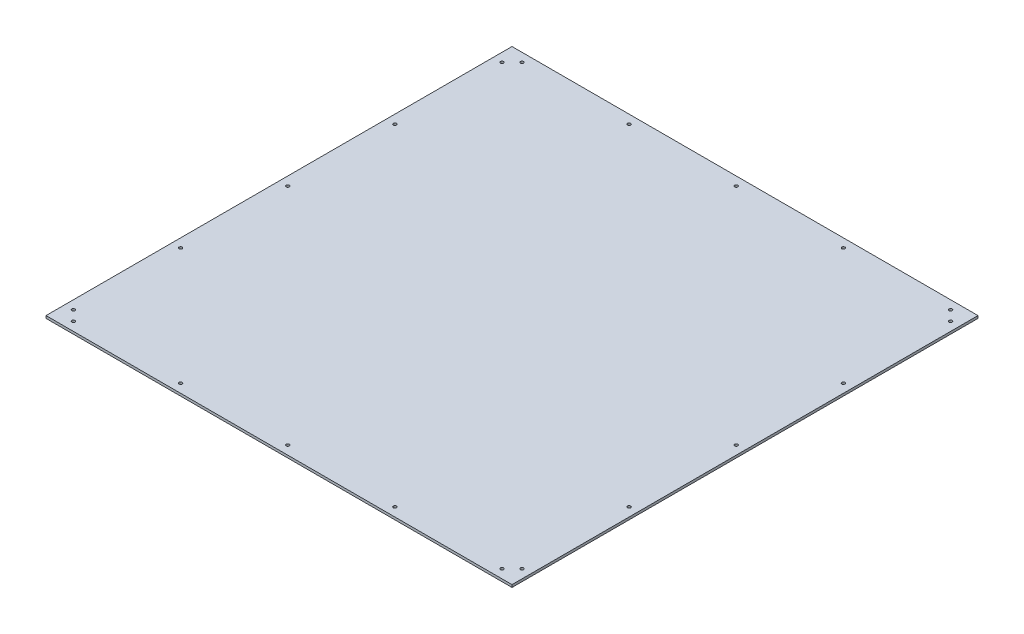
from build123d import *

# Parameters (mm, degrees)
SKETCH1_W           = 748
SKETCH1_H           = 748
SKETCH1_R           = 2.5
BOSS_EXTRUDE1_DEPTH = 4


with BuildPart() as part:
    # Sketch1 → Boss-Extrude1 (new body)
    with BuildSketch(Plane(origin=(0, 0, 0), x_dir=(1, 0, 0), z_dir=(0, 1, 0))):
        Rectangle(SKETCH1_W, SKETCH1_H)
        with Locations((-344, 360)):
            Circle(SKETCH1_R, mode=Mode.SUBTRACT)
        with Locations((0, 360)):
            Circle(SKETCH1_R, mode=Mode.SUBTRACT)
        with Locations((-172, 360)):
            Circle(SKETCH1_R, mode=Mode.SUBTRACT)
        with Locations((-360, 0)):
            Circle(SKETCH1_R, mode=Mode.SUBTRACT)
        with Locations((-360, 172)):
            Circle(SKETCH1_R, mode=Mode.SUBTRACT)
        with Locations((-360, 344)):
            Circle(SKETCH1_R, mode=Mode.SUBTRACT)
        with Locations((360, 0)):
            Circle(SKETCH1_R, mode=Mode.SUBTRACT)
        with Locations((172, 360)):
            Circle(SKETCH1_R, mode=Mode.SUBTRACT)
        with Locations((360, 344)):
            Circle(SKETCH1_R, mode=Mode.SUBTRACT)
        with Locations((360, 172)):
            Circle(SKETCH1_R, mode=Mode.SUBTRACT)
        with Locations((344, 360)):
            Circle(SKETCH1_R, mode=Mode.SUBTRACT)
        with Locations((360, -172)):
            Circle(SKETCH1_R, mode=Mode.SUBTRACT)
        with Locations((360, -344)):
            Circle(SKETCH1_R, mode=Mode.SUBTRACT)
        with Locations((344, -360)):
            Circle(SKETCH1_R, mode=Mode.SUBTRACT)
        with Locations((172, -360)):
            Circle(SKETCH1_R, mode=Mode.SUBTRACT)
        with Locations((0, -360)):
            Circle(SKETCH1_R, mode=Mode.SUBTRACT)
        with Locations((-172, -360)):
            Circle(SKETCH1_R, mode=Mode.SUBTRACT)
        with Locations((-344, -360)):
            Circle(SKETCH1_R, mode=Mode.SUBTRACT)
        with Locations((-360, -344)):
            Circle(SKETCH1_R, mode=Mode.SUBTRACT)
        with Locations((-360, -172)):
            Circle(SKETCH1_R, mode=Mode.SUBTRACT)
    extrude(amount=BOSS_EXTRUDE1_DEPTH)


solid = part.part
